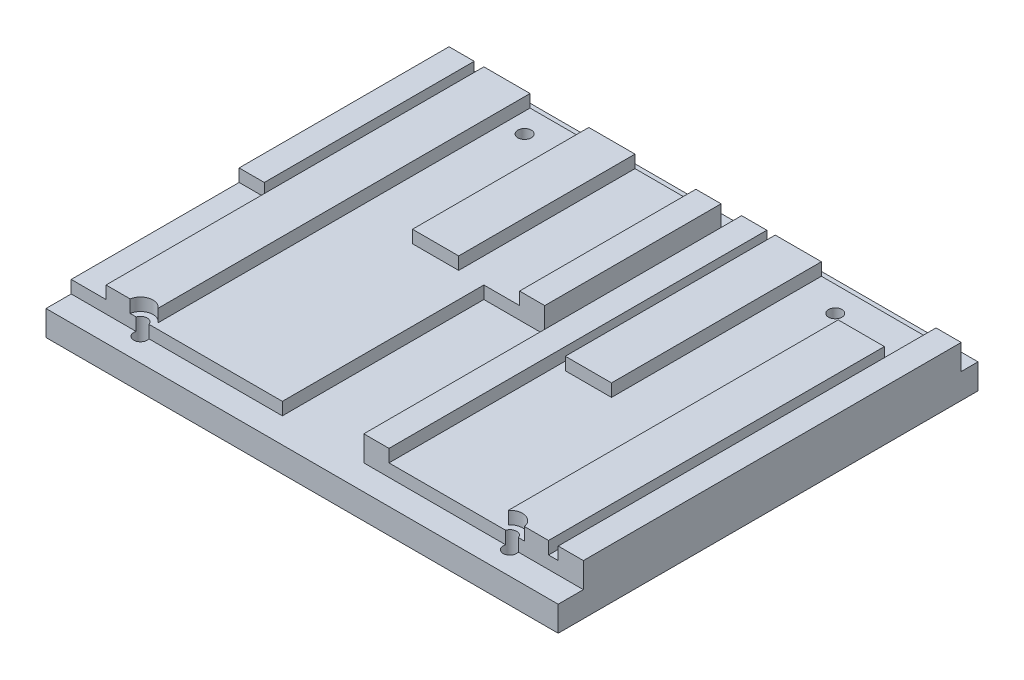
from build123d import *

# Parameters (mm, degrees)
SKETCH1_W           = 122
SKETCH1_H           = 100
BOSS_EXTRUDE1_DEPTH = 3
SKETCH2_W           = 5
SKETCH2_H           = 47
CUT_EXTRUDE1_DEPTH  = 4
SKETCH3_W           = 52.3
SKETCH3_H           = 90
BOSS_EXTRUDE2_DEPTH = 3
SKETCH4_W           = 6
SKETCH4_H           = 50
SKETCH4_W_2         = 11
SKETCH4_H_2         = 90
SKETCH4_H_3         = 42
SKETCH4_H_4         = 80
BOSS_EXTRUDE3_DEPTH = 3
SKETCH7_W           = 122
SKETCH7_H           = 100
SKETCH7_W_2         = 14.9
SKETCH7_H_2         = 46
BOSS_EXTRUDE5_DEPTH = 3
SKETCH8_R           = 1.6
CUT_EXTRUDE2_DEPTH  = 13
CUT_EXTRUDE3_START  = 3
SKETCH9_R           = 3
CUT_EXTRUDE3_DEPTH  = 4


with BuildPart() as part:
    # Sketch1 → Boss-Extrude1 (new body)
    with BuildSketch(Plane(origin=(0, 0, 0), x_dir=(1, 0, 0), z_dir=(0, 1, 0))):
        with Locations((61, 50)):
            Rectangle(SKETCH1_W, SKETCH1_H)
    extrude(amount=BOSS_EXTRUDE1_DEPTH)

    # Sketch2 → Cut-Extrude1 (cut, through all)
    with BuildSketch(Plane(origin=(0, 3, 0), x_dir=(1, 0, 0), z_dir=(0, 1, 0))):
        with Locations((67.3, 76.5)):
            Rectangle(SKETCH2_W, SKETCH2_H)
    extrude(amount=-CUT_EXTRUDE1_DEPTH, mode=Mode.SUBTRACT)

    # Sketch3 → Boss-Extrude2 (add)
    with BuildSketch(Plane(origin=(0, 3, 0), x_dir=(1, 0, 0), z_dir=(0, 1, 0))):
        Polygon((0, 96), (64.8, 96), (64.8, 54), (50.3, 54), (50.3, 6), (0, 6), align=None)
        with Locations((95.85, 51)):
            Rectangle(SKETCH3_W, SKETCH3_H)
    extrude(amount=BOSS_EXTRUDE2_DEPTH)

    # Sketch4 → Boss-Extrude3 (add)
    with BuildSketch(Plane(origin=(0, 6, 0), x_dir=(1, 0, 0), z_dir=(0, 1, 0))):
        with Locations((3, 71)):
            Rectangle(SKETCH4_W, SKETCH4_H)
        with Locations((13.8, 51)):
            Rectangle(SKETCH4_W_2, SKETCH4_H_2)
        with Locations((38.8, 75)):
            Rectangle(SKETCH4_W_2, SKETCH4_H_3)
        with Locations((61.8, 75)):
            Rectangle(SKETCH4_W, SKETCH4_H_3)
        with Locations((83.2, 71)):
            Rectangle(SKETCH4_W_2, SKETCH4_H)
        with Locations((108.2, 46)):
            Rectangle(SKETCH4_W_2, SKETCH4_H_4)
        with Locations((119, 51)):
            Rectangle(SKETCH4_W, SKETCH4_H_2)
        with Locations((72.7, 51)):
            Rectangle(SKETCH4_W, SKETCH4_H_2)
    extrude(amount=BOSS_EXTRUDE3_DEPTH)

    # Sketch7 → Boss-Extrude5 (add)
    with BuildSketch(Plane.XZ):
        with Locations((61, -50)):
            Rectangle(SKETCH7_W, SKETCH7_H)
        with Locations((67.25, -72)):
            Rectangle(SKETCH7_W_2, SKETCH7_H_2, mode=Mode.SUBTRACT)
    extrude(amount=BOSS_EXTRUDE5_DEPTH)

    # Sketch8 → Cut-Extrude2 (cut, through all)
    with BuildSketch(Plane.XZ.offset(3)):
        with Locations((105, -5.5)):
            Circle(SKETCH8_R)
        with Locations((17, -5.5)):
            Circle(SKETCH8_R)
        with Locations((24, -90)):
            Circle(SKETCH8_R)
        with Locations((98, -90)):
            Circle(SKETCH8_R)
    extrude(amount=-CUT_EXTRUDE2_DEPTH, mode=Mode.SUBTRACT)

    # Sketch9 → Cut-Extrude3 (cut, through all)
    with BuildSketch(Plane(origin=(0, 3, 0), x_dir=(1, 0, 0), z_dir=(0, 1, 0)).offset(CUT_EXTRUDE3_START)):
        with Locations((17, 5.5)):
            Circle(SKETCH9_R)
        with Locations((105, 5.5)):
            Circle(SKETCH9_R)
    extrude(amount=CUT_EXTRUDE3_DEPTH, mode=Mode.SUBTRACT)


solid = part.part
